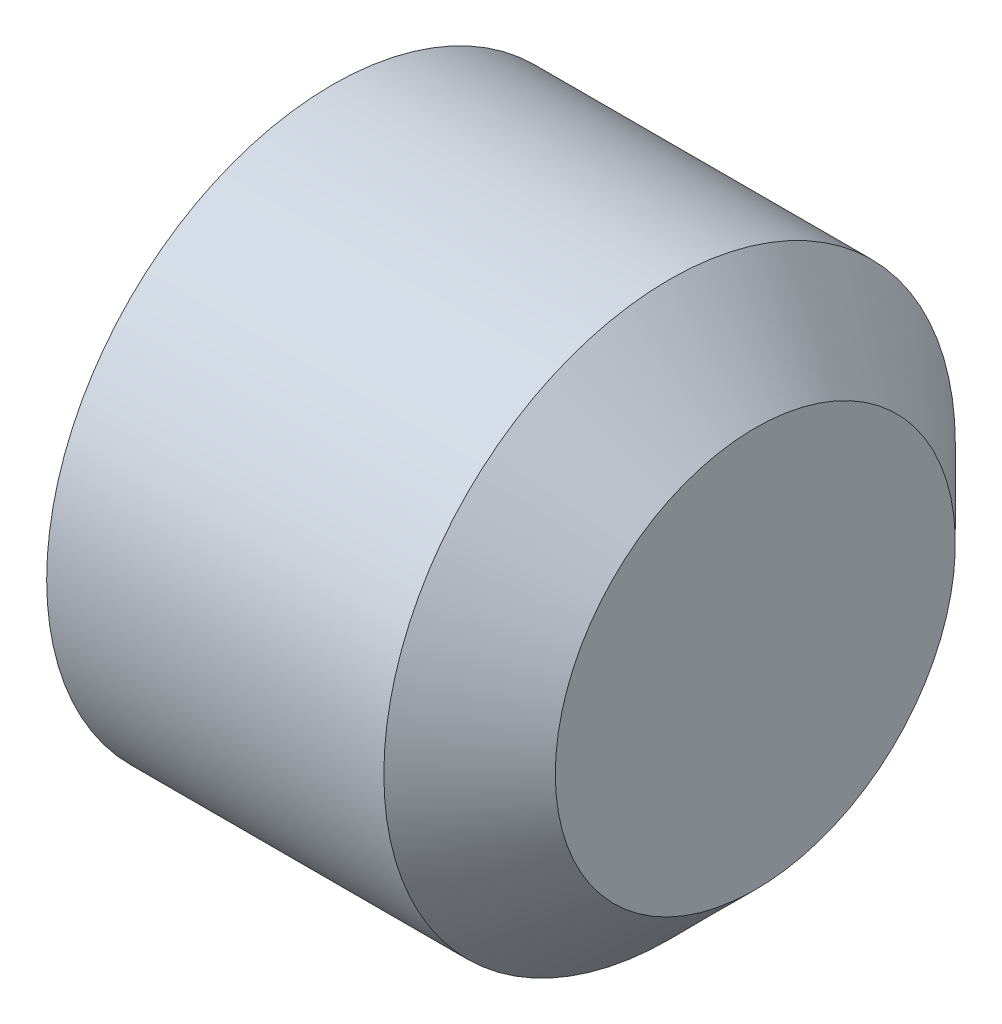
from build123d import *

# Parameters (mm, degrees)
SKETCH1_W          = 4
SKETCH1_H          = 2.5
CUT_EXTRUDE1_DEPTH = 2
CHAMFER1_SIZE      = 0.75
CHAMFER2_SIZE      = 0.3
CHAMFER2_SIZE2     = 0.5


with BuildPart() as part:
    # Sketch1 → Revolve1 (revolve)
    with BuildSketch(Plane.XY):
        with Locations((2, 1.25)):
            Rectangle(SKETCH1_W, SKETCH1_H)
    revolve(axis=Axis((-0.394679187, 0, 0), (1, 0, 0)))

    # Sketch2 → Cut-Extrude1 (cut)
    with BuildSketch(Plane(origin=(0, 0, 0), x_dir=(0, 0, -1), z_dir=(1, 0, 0))):
        Polygon((-0.721687836, 1.25), (-1.443375673, 0), (-0.721687836, -1.25), (0.721687836, -1.25), (1.443375673, 0), (0.721687836, 1.25), align=None)
    extrude(amount=CUT_EXTRUDE1_DEPTH, mode=Mode.SUBTRACT)

    # Chamfer1
    chamfer1_edges = [part.edges().sort_by_distance(p)[0] for p in [
        (4, -2.5, 0),
    ]]
    chamfer(chamfer1_edges, length=CHAMFER1_SIZE)

    # Chamfer2
    chamfer2_edges = [part.edges().sort_by_distance(p)[0] for p in [
        (0, -2.5, 0),
    ]]
    chamfer2_side = [part.faces().sort_by_distance(p)[0] for p in [
        (1.625, -2.5, 0),
    ]]
    chamfer(chamfer2_edges, length=CHAMFER2_SIZE, length2=CHAMFER2_SIZE2, reference=chamfer2_side[0])


solid = part.part
